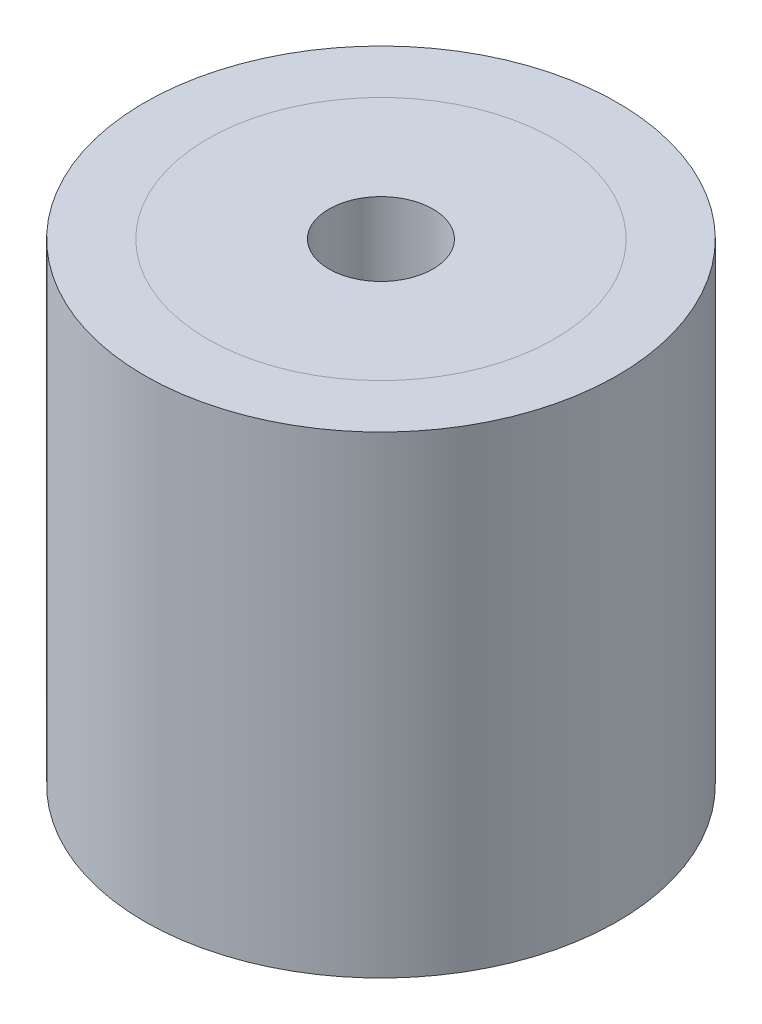
from build123d import *

# Parameters (mm, degrees)
SKETCH_1_R             = 7.5
EXTRUDE_1_DEPTH        = 7.5
HOLE_WIZARD_M4_1_D     = 3.3
HOLE_WIZARD_M4_1_DEPTH = 21.5
HOLE_WIZARD_M4_1_TIP   = 0.991420021


with BuildPart() as part:
    # 草图1 → 凸台-拉伸1 (new body, symmetric)
    with BuildSketch(Plane(origin=(0, 0, 0), x_dir=(1, 0, 0), z_dir=(0, 1, 0))):
        Circle(SKETCH_1_R)
    extrude(amount=EXTRUDE_1_DEPTH, both=True)

    # M4 螺纹孔1
    with Locations(Plane(origin=(0, 7.5, 0), x_dir=(1, 0, 0), z_dir=(0, 1, 0))):
        with Locations((0, 0)):
            Hole(HOLE_WIZARD_M4_1_D / 2, depth=HOLE_WIZARD_M4_1_DEPTH)
            with Locations((0, 0, -(HOLE_WIZARD_M4_1_DEPTH + HOLE_WIZARD_M4_1_TIP / 2))):  # 118° drill point
                Cone(0, HOLE_WIZARD_M4_1_D / 2, HOLE_WIZARD_M4_1_TIP, mode=Mode.SUBTRACT)


solid = part.part
